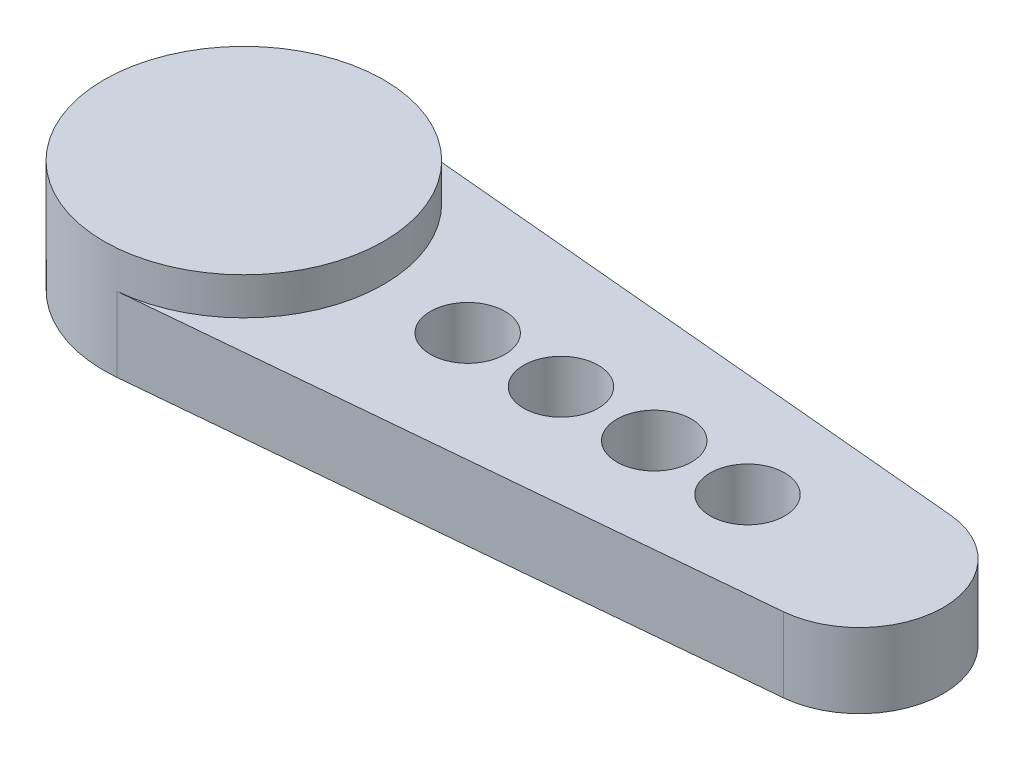
from build123d import *

# Parameters (mm, degrees)
SKETCH1_R           = 1
BOSS_EXTRUDE1_DEPTH = 2
SKETCH2_R           = 3.75
BOSS_EXTRUDE2_DEPTH = 1
SKETCH3_R           = 2.75
CUT_EXTRUDE1_DEPTH  = 1


with BuildPart() as part:
    # Sketch1 → Boss-Extrude1 (new body)
    with BuildSketch(Plane(origin=(0, 0, 0), x_dir=(1, 0, 0), z_dir=(0, 1, 0))):
        with BuildLine():
            Line((0.340909091, 3.734471983), (16.704545455, 2.24068319))
            ThreePointArc((16.704545455, 2.24068319), (18.75, 0), (16.704545455, -2.24068319))
            Line((16.704545455, -2.24068319), (0.340909091, -3.734471983))
            ThreePointArc((0.340909091, -3.734471983), (-3.75, 0), (0.340909091, 3.734471983))
        make_face()
        with Locations((6, 0)):
            Circle(SKETCH1_R, mode=Mode.SUBTRACT)
        with Locations((8.5, 0)):
            Circle(SKETCH1_R, mode=Mode.SUBTRACT)
        with Locations((11, 0)):
            Circle(SKETCH1_R, mode=Mode.SUBTRACT)
        with Locations((13.5, 0)):
            Circle(SKETCH1_R, mode=Mode.SUBTRACT)
    extrude(amount=BOSS_EXTRUDE1_DEPTH)

    # Sketch2 → Boss-Extrude2 (add)
    with BuildSketch(Plane(origin=(0, 2, 0), x_dir=(1, 0, 0), z_dir=(0, 1, 0))):
        Circle(SKETCH2_R)
    extrude(amount=BOSS_EXTRUDE2_DEPTH)

    # Sketch3 → Cut-Extrude1 (cut)
    with BuildSketch(Plane.XZ):
        Circle(SKETCH3_R)
    extrude(amount=-CUT_EXTRUDE1_DEPTH, mode=Mode.SUBTRACT)


solid = part.part
